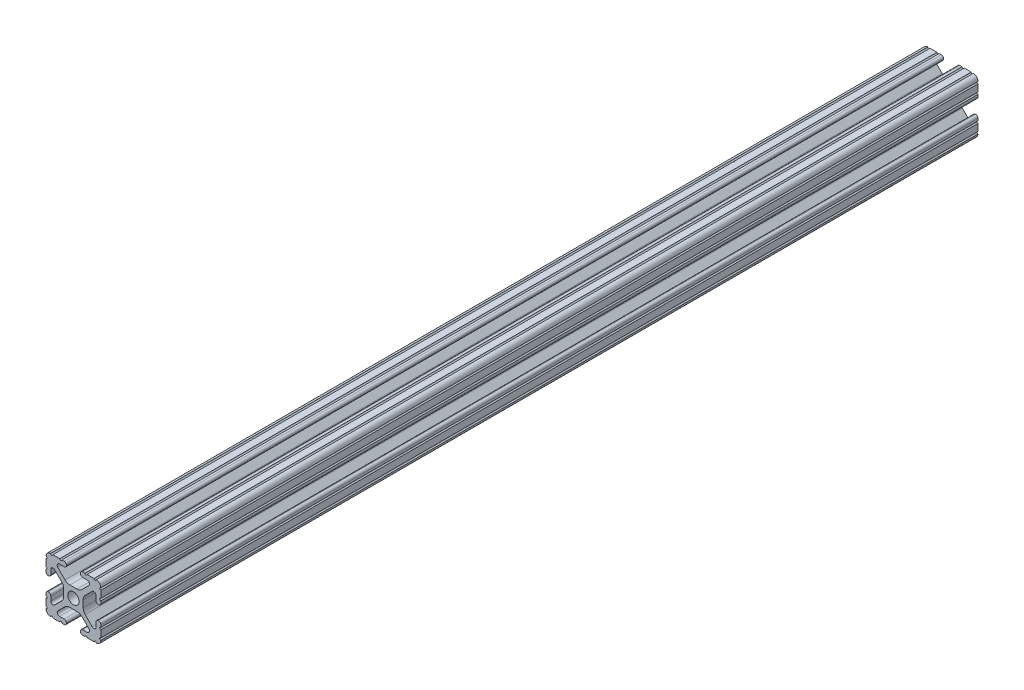
from build123d import *

# Parameters (mm, degrees)
SKETCH1_R           = 2.6035
BOSS_EXTRUDE1_DEPTH = 304.8
SKETCH2_R           = 37.713648337
CUT_EXTRUDE1_DEPTH  = 203.2


with BuildPart() as part:
    # Sketch1 → Boss-Extrude1 (new, symmetric)
    with BuildSketch(Plane.XY):
        with BuildLine():
            Line((-7.179650497, -8.645192506), (-3.952270251, -5.423690499))
            ThreePointArc((-3.952270251, -5.423690499), (-2.922936451, -4.736929036), (-1.709253557, -4.4958))
            Line((-1.709253557, -4.4958), (1.709253557, -4.4958))
            ThreePointArc((1.709253557, -4.4958), (2.922936451, -4.736929036), (3.952270251, -5.423690499))
            Line((3.952270251, -5.423690499), (7.179650497, -8.645192506))
            ThreePointArc((7.179650497, -8.645192506), (7.41473083, -9.822813117), (6.416408329, -10.4902))
            Line((6.416408329, -10.4902), (4.287512407, -10.4902))
            ThreePointArc((4.287512407, -10.4902), (3.54574862, -10.79744862), (3.2385, -11.539212407))
            Line((3.2385, -11.539212407), (3.2385, -11.650987593))
            ThreePointArc((3.2385, -11.650987593), (3.54574862, -12.39275138), (4.287512407, -12.7))
            Line((4.287512407, -12.7), (5.317126718, -12.7))
            ThreePointArc((5.317126718, -12.7), (5.825126718, -12.192), (6.333126718, -12.7))
            Line((6.333126718, -12.7), (9.550443118, -12.7))
            ThreePointArc((9.550443118, -12.7), (10.058366869, -12.192000006), (10.566443095, -12.699847501))
            ThreePointArc((10.566443095, -12.699847501), (12.082537762, -12.08250727), (12.699846982, -10.566399977))
            ThreePointArc((12.699846982, -10.566399977), (12.192000006, -10.058323491), (12.7, -9.5504))
            Line((12.7, -9.5504), (12.7, -6.3330836))
            ThreePointArc((12.7, -6.3330836), (12.192, -5.8250836), (12.7, -5.3170836))
            Line((12.7, -5.3170836), (12.7, -4.287469289))
            ThreePointArc((12.7, -4.287469289), (12.39275138, -3.545705502), (11.650987593, -3.238456882))
            Line((11.650987593, -3.238456882), (11.539212407, -3.238456882))
            ThreePointArc((11.539212407, -3.238456882), (10.79744862, -3.545705502), (10.4902, -4.287469289))
            Line((10.4902, -4.287469289), (10.4902, -6.402089023))
            ThreePointArc((10.4902, -6.402089023), (9.856505071, -7.351067942), (8.737131347, -7.129408934))
            Line((8.737131347, -7.129408934), (5.441005833, -3.840816462))
            ThreePointArc((5.441005833, -3.840816462), (4.750877967, -2.809883091), (4.5085, -1.593185507))
            Line((4.5085, -1.593185507), (4.5085, 1.593185507))
            ThreePointArc((4.5085, 1.593185507), (4.750877967, 2.809883091), (5.441005833, 3.840816462))
            Line((5.441005833, 3.840816462), (8.737131347, 7.129408934))
            ThreePointArc((8.737131347, 7.129408934), (9.856505071, 7.351067942), (10.4902, 6.402089023))
            Line((10.4902, 6.402089023), (10.4902, 4.287469289))
            ThreePointArc((10.4902, 4.287469289), (10.79744862, 3.545705502), (11.539212407, 3.238456882))
            Line((11.539212407, 3.238456882), (11.650987593, 3.238456882))
            ThreePointArc((11.650987593, 3.238456882), (12.39275138, 3.545705502), (12.7, 4.287469289))
            Line((12.7, 4.287469289), (12.7, 5.3170836))
            ThreePointArc((12.7, 5.3170836), (12.192, 5.8250836), (12.7, 6.3330836))
            Line((12.7, 6.3330836), (12.7, 9.5504))
            ThreePointArc((12.7, 9.5504), (12.192000006, 10.058323491), (12.699846982, 10.566399977))
            ThreePointArc((12.699846982, 10.566399977), (12.082537762, 12.08250727), (10.566443095, 12.699847501))
            ThreePointArc((10.566443095, 12.699847501), (10.058366869, 12.192000006), (9.550443118, 12.7))
            Line((9.550443118, 12.7), (6.333126718, 12.7))
            ThreePointArc((6.333126718, 12.7), (5.825126718, 12.192), (5.317126718, 12.7))
            Line((5.317126718, 12.7), (4.287512407, 12.7))
            ThreePointArc((4.287512407, 12.7), (3.54574862, 12.39275138), (3.2385, 11.650987593))
            Line((3.2385, 11.650987593), (3.2385, 11.539212407))
            ThreePointArc((3.2385, 11.539212407), (3.54574862, 10.79744862), (4.287512407, 10.4902))
            Line((4.287512407, 10.4902), (6.476788598, 10.4902))
            ThreePointArc((6.476788598, 10.4902), (7.432222385, 9.85140422), (7.207036008, 8.724370562))
            Line((7.207036008, 8.724370562), (3.898272566, 5.423169045))
            ThreePointArc((3.898272566, 5.423169045), (2.869120213, 4.736787962), (1.655778399, 4.4958))
            Line((1.655778399, 4.4958), (-1.655778399, 4.4958))
            ThreePointArc((-1.655778399, 4.4958), (-2.869120213, 4.736787962), (-3.898272566, 5.423169045))
            Line((-3.898272566, 5.423169045), (-7.207036008, 8.724370562))
            ThreePointArc((-7.207036008, 8.724370562), (-7.432222385, 9.85140422), (-6.476788598, 10.4902))
            Line((-6.476788598, 10.4902), (-4.287512407, 10.4902))
            ThreePointArc((-4.287512407, 10.4902), (-3.54574862, 10.79744862), (-3.2385, 11.539212407))
            Line((-3.2385, 11.539212407), (-3.2385, 11.650987593))
            ThreePointArc((-3.2385, 11.650987593), (-3.54574862, 12.39275138), (-4.287512407, 12.7))
            Line((-4.287512407, 12.7), (-5.317126718, 12.7))
            ThreePointArc((-5.317126718, 12.7), (-5.825126718, 12.192), (-6.333126718, 12.7))
            Line((-6.333126718, 12.7), (-9.550443118, 12.7))
            ThreePointArc((-9.550443118, 12.7), (-10.058366869, 12.192000006), (-10.566443095, 12.699847501))
            ThreePointArc((-10.566443095, 12.699847501), (-12.082537762, 12.08250727), (-12.699846982, 10.566399977))
            ThreePointArc((-12.699846982, 10.566399977), (-12.192000006, 10.058323491), (-12.7, 9.5504))
            Line((-12.7, 9.5504), (-12.7, 6.3330836))
            ThreePointArc((-12.7, 6.3330836), (-12.192, 5.8250836), (-12.7, 5.3170836))
            Line((-12.7, 5.3170836), (-12.7, 4.287469289))
            ThreePointArc((-12.7, 4.287469289), (-12.39275138, 3.545705502), (-11.650987593, 3.238456882))
            Line((-11.650987593, 3.238456882), (-11.539212407, 3.238456882))
            ThreePointArc((-11.539212407, 3.238456882), (-10.79744862, 3.545705502), (-10.4902, 4.287469289))
            Line((-10.4902, 4.287469289), (-10.4902, 6.402089023))
            ThreePointArc((-10.4902, 6.402089023), (-9.856505071, 7.351067942), (-8.737131347, 7.129408934))
            Line((-8.737131347, 7.129408934), (-5.441005833, 3.840816462))
            ThreePointArc((-5.441005833, 3.840816462), (-4.750877967, 2.809883091), (-4.5085, 1.593185507))
            Line((-4.5085, 1.593185507), (-4.5085, -1.593185507))
            ThreePointArc((-4.5085, -1.593185507), (-4.750877967, -2.809883091), (-5.441005833, -3.840816462))
            Line((-5.441005833, -3.840816462), (-8.737131347, -7.129408934))
            ThreePointArc((-8.737131347, -7.129408934), (-9.856505071, -7.351067942), (-10.4902, -6.402089023))
            Line((-10.4902, -6.402089023), (-10.4902, -4.287469289))
            ThreePointArc((-10.4902, -4.287469289), (-10.79744862, -3.545705502), (-11.539212407, -3.238456882))
            Line((-11.539212407, -3.238456882), (-11.650987593, -3.238456882))
            ThreePointArc((-11.650987593, -3.238456882), (-12.39275138, -3.545705502), (-12.7, -4.287469289))
            Line((-12.7, -4.287469289), (-12.7, -5.3170836))
            ThreePointArc((-12.7, -5.3170836), (-12.192, -5.8250836), (-12.7, -6.3330836))
            Line((-12.7, -6.3330836), (-12.7, -9.5504))
            ThreePointArc((-12.7, -9.5504), (-12.192000006, -10.058323491), (-12.699846982, -10.566399977))
            ThreePointArc((-12.699846982, -10.566399977), (-12.082537762, -12.08250727), (-10.566443095, -12.699847501))
            ThreePointArc((-10.566443095, -12.699847501), (-10.058366869, -12.192000006), (-9.550443118, -12.7))
            Line((-9.550443118, -12.7), (-6.333126718, -12.7))
            ThreePointArc((-6.333126718, -12.7), (-5.825126718, -12.192), (-5.317126718, -12.7))
            Line((-5.317126718, -12.7), (-4.287512407, -12.7))
            ThreePointArc((-4.287512407, -12.7), (-3.54574862, -12.39275138), (-3.2385, -11.650987593))
            Line((-3.2385, -11.650987593), (-3.2385, -11.539212407))
            ThreePointArc((-3.2385, -11.539212407), (-3.54574862, -10.79744862), (-4.287512407, -10.4902))
            Line((-4.287512407, -10.4902), (-6.416408329, -10.4902))
            ThreePointArc((-6.416408329, -10.4902), (-7.41473083, -9.822813117), (-7.179650497, -8.645192506))
        make_face()
        Circle(SKETCH1_R, mode=Mode.SUBTRACT)
    extrude(amount=BOSS_EXTRUDE1_DEPTH, both=True)

    # Sketch2 → Cut-Extrude1 (cut)
    with BuildSketch(Plane.XY.offset(304.8)):
        Circle(SKETCH2_R)
    extrude(amount=-CUT_EXTRUDE1_DEPTH, mode=Mode.SUBTRACT)


solid = part.part
